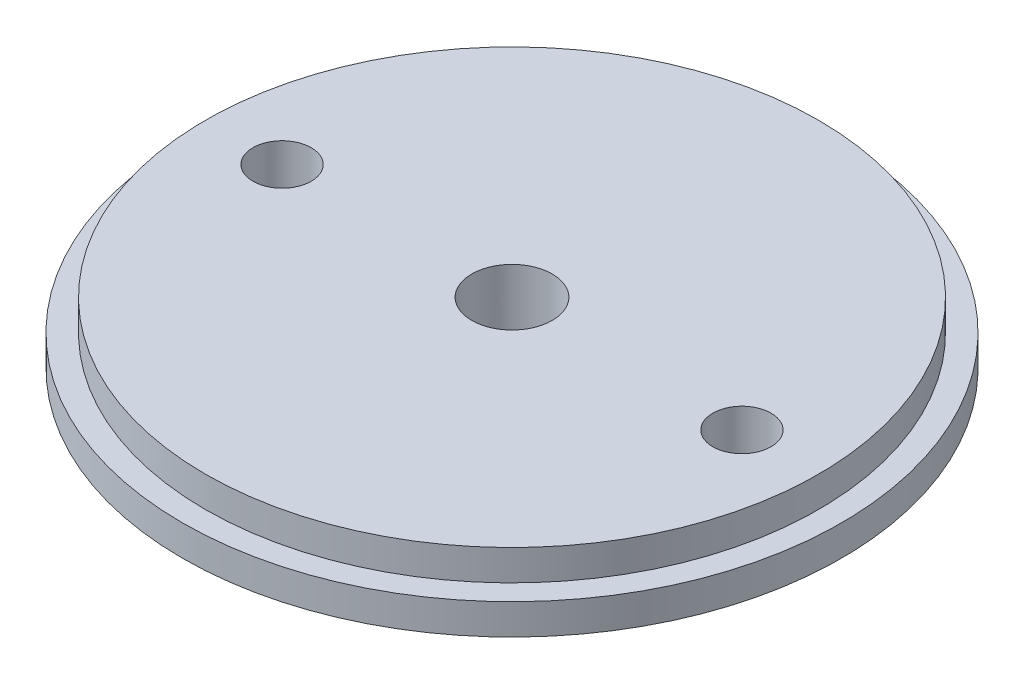
from build123d import *

# Parameters (mm, degrees)
SKETCH1_R           = 27.305
BOSS_EXTRUDE1_DEPTH = 2.54
SKETCH2_R           = 25.4
BOSS_EXTRUDE2_DEPTH = 2.54
CUT_EXTRUDE1_REACH  = 7.08
SKETCH3_R           = 3.334616924
SKETCH3_R_2         = 2.413


with BuildPart() as part:
    # Sketch1 → Boss-Extrude1 (new body)
    with BuildSketch(Plane(origin=(0, 0, 0), x_dir=(1, 0, 0), z_dir=(0, 1, 0))):
        Circle(SKETCH1_R)
    extrude(amount=BOSS_EXTRUDE1_DEPTH)

    # Sketch2 → Boss-Extrude2 (add)
    with BuildSketch(Plane(origin=(0, 2.54, 0), x_dir=(1, 0, 0), z_dir=(0, 1, 0))):
        Circle(SKETCH2_R)
    extrude(amount=BOSS_EXTRUDE2_DEPTH)

    # Sketch3 → Cut-Extrude1 (cut, up to next)
    with BuildSketch(Plane.XZ, mode=Mode.PRIVATE) as cut_extrude1_sk1:
        Circle(SKETCH3_R)
    cut_extrude1_tool1 = extrude(cut_extrude1_sk1.sketch, amount=-CUT_EXTRUDE1_REACH, mode=Mode.PRIVATE) & part.part
    add(cut_extrude1_tool1.solids().sort_by_distance((0, 0, 0))[0], mode=Mode.SUBTRACT)
    # Sketch3 → Cut-Extrude1 (cut, up to next)
    with BuildSketch(Plane.XZ, mode=Mode.PRIVATE) as cut_extrude1_sk2:
        with Locations((-19.05, 0)):
            Circle(SKETCH3_R_2)
    cut_extrude1_tool2 = extrude(cut_extrude1_sk2.sketch, amount=-CUT_EXTRUDE1_REACH, mode=Mode.PRIVATE) & part.part
    add(cut_extrude1_tool2.solids().sort_by_distance((-19.05, 0, 0))[0], mode=Mode.SUBTRACT)
    # Sketch3 → Cut-Extrude1 (cut, up to next)
    with BuildSketch(Plane.XZ, mode=Mode.PRIVATE) as cut_extrude1_sk3:
        with Locations((19.05, 0)):
            Circle(SKETCH3_R_2)
    cut_extrude1_tool3 = extrude(cut_extrude1_sk3.sketch, amount=-CUT_EXTRUDE1_REACH, mode=Mode.PRIVATE) & part.part
    add(cut_extrude1_tool3.solids().sort_by_distance((19.05, 0, 0))[0], mode=Mode.SUBTRACT)


solid = part.part
